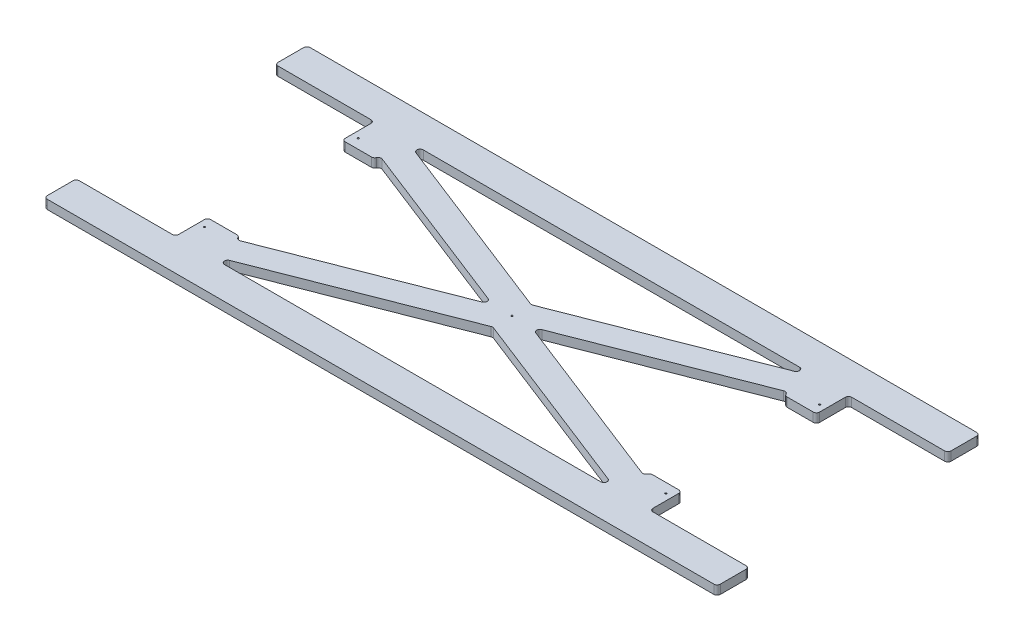
from build123d import *

# Parameters (mm, degrees)
SKETCH1_W                    = 1333.5
SKETCH1_H                    = 520.7
BOSS_EXTRUDE1_DEPTH          = 17.78
FILLET1_R                    = 6.35
F_1_8_0_125_DIAMETER_HOLE1_D = 3.175
SKETCH5_W                    = 152.4
SKETCH5_H                    = 393.7
CUT_EXTRUDE1_DEPTH           = 18.78
FILLET2_R                    = 6.35
SKETCH6_W                    = 50.8
SKETCH6_H                    = 393.7
SKETCH6_W_2                  = 63.5
SKETCH6_H_2                  = 266.7
CUT_EXTRUDE2_DEPTH           = 18.78
FILLET3_R                    = 6.35


with BuildPart() as part:
    # Sketch1 → Boss-Extrude1 (new body)
    with BuildSketch(Plane(origin=(0, 0, 0), x_dir=(1, 0, 0), z_dir=(0, 1, 0))):
        Rectangle(SKETCH1_W, SKETCH1_H)
    extrude(amount=BOSS_EXTRUDE1_DEPTH)

    # Fillet1
    fillet1_edges = [part.edges().sort_by_distance(p)[0] for p in [
        (666.75, 8.89, 260.35),
        (-666.75, 8.89, 260.35),
        (-666.75, 8.89, -260.35),
        (666.75, 8.89, -260.35),
    ]]
    fillet(fillet1_edges, radius=FILLET1_R)

    # 1/8 (0.125) Diameter Hole1 (through all)
    with Locations(Plane(origin=(0, 17.78, 0), x_dir=(1, 0, 0), z_dir=(0, 1, 0))):
        with Locations((0, 0), (457.2, 152.4), (-457.2, -152.4), (-457.2, 152.4), (457.2, -152.4)):
            Hole(F_1_8_0_125_DIAMETER_HOLE1_D / 2)

    # Sketch5 → Cut-Extrude1 (cut, through all)
    with BuildSketch(Plane(origin=(0, 17.78, 0), x_dir=(1, 0, 0), z_dir=(0, 1, 0))):
        Polygon((-406.4, 196.85), (406.4, 196.85), (0, 38.1), align=None)
        Polygon((0, -38.1), (-406.4, -196.85), (406.4, -196.85), align=None)
        Polygon((406.4, 143.8671875), (406.4, -143.8671875), (38.1, 0), align=None)
        Polygon((-406.4, 143.8671875), (-38.1, 0), (-406.4, -143.8671875), align=None)
        with Locations((546.1, 0)):
            Rectangle(SKETCH5_W, SKETCH5_H)
        with Locations((-546.1, 0)):
            Rectangle(SKETCH5_W, SKETCH5_H)
    extrude(amount=-CUT_EXTRUDE1_DEPTH, mode=Mode.SUBTRACT)

    # Fillet2
    fillet2_edges = [part.edges().sort_by_distance(p)[0] for p in [
        (-406.4, 8.89, 143.8671875),
        (-406.4, 8.89, -143.8671875),
        (-38.1, 8.89, 0),
        (622.3, 8.89, -196.85),
        (622.3, 8.89, 196.85),
        (469.9, 8.89, 196.85),
        (469.9, 8.89, -196.85),
        (0, 8.89, 38.1),
        (406.4, 8.89, 196.85),
        (-406.4, 8.89, 196.85),
        (38.1, 8.89, 0),
        (406.4, 8.89, -143.8671875),
        (406.4, 8.89, 143.8671875),
        (406.4, 8.89, -196.85),
        (0, 8.89, -38.1),
        (-406.4, 8.89, -196.85),
        (-469.9, 8.89, -196.85),
        (-469.9, 8.89, 196.85),
        (-622.3, 8.89, 196.85),
        (-622.3, 8.89, -196.85),
    ]]
    fillet(fillet2_edges, radius=FILLET2_R)

    # Sketch6 → Cut-Extrude2 (cut, through all)
    with BuildSketch(Plane(origin=(0, 17.78, 0), x_dir=(1, 0, 0), z_dir=(0, 1, 0))):
        with Locations((641.35, 0)):
            Rectangle(SKETCH6_W, SKETCH6_H)
        with Locations((-641.35, 0)):
            Rectangle(SKETCH6_W, SKETCH6_H)
        with Locations((-438.15, 0)):
            Rectangle(SKETCH6_W_2, SKETCH6_H_2)
        with Locations((438.15, 0)):
            Rectangle(SKETCH6_W_2, SKETCH6_H_2)
    extrude(amount=-CUT_EXTRUDE2_DEPTH, mode=Mode.SUBTRACT)

    # Fillet3
    fillet3_edges = [part.edges().sort_by_distance(p)[0] for p in [
        (-666.75, 8.89, 196.85),
        (-666.75, 8.89, -196.85),
        (666.75, 8.89, -196.85),
        (666.75, 8.89, 196.85),
        (-406.4, 8.89, 133.35),
        (-406.4, 8.89, -133.35),
        (-469.9, 8.89, 133.35),
        (-469.9, 8.89, -133.35),
        (469.9, 8.89, -133.35),
        (406.4, 8.89, -133.35),
        (469.9, 8.89, 133.35),
        (406.4, 8.89, 133.35),
    ]]
    fillet(fillet3_edges, radius=FILLET3_R)


solid = part.part
